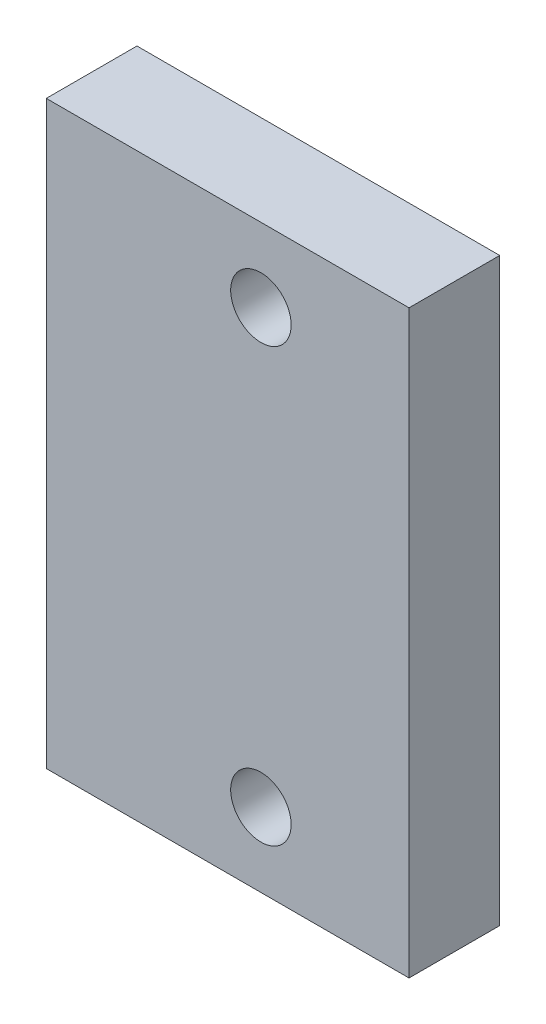
from build123d import *

# Parameters (mm, degrees)
SKETCH1_W           = 60
SKETCH1_H           = 96
SKETCH1_R           = 5
BOSS_EXTRUDE1_DEPTH = 15


with BuildPart() as part:
    # Sketch1 → Boss-Extrude1 (new body)
    with BuildSketch(Plane.XY):
        with Locations((30, 268.509389187)):
            Rectangle(SKETCH1_W, SKETCH1_H)
        with Locations((35.5, 232.728933645)):
            Circle(SKETCH1_R, mode=Mode.SUBTRACT)
        with Locations((35.5, 304.28984473)):
            Circle(SKETCH1_R, mode=Mode.SUBTRACT)
    extrude(amount=BOSS_EXTRUDE1_DEPTH)


solid = part.part
